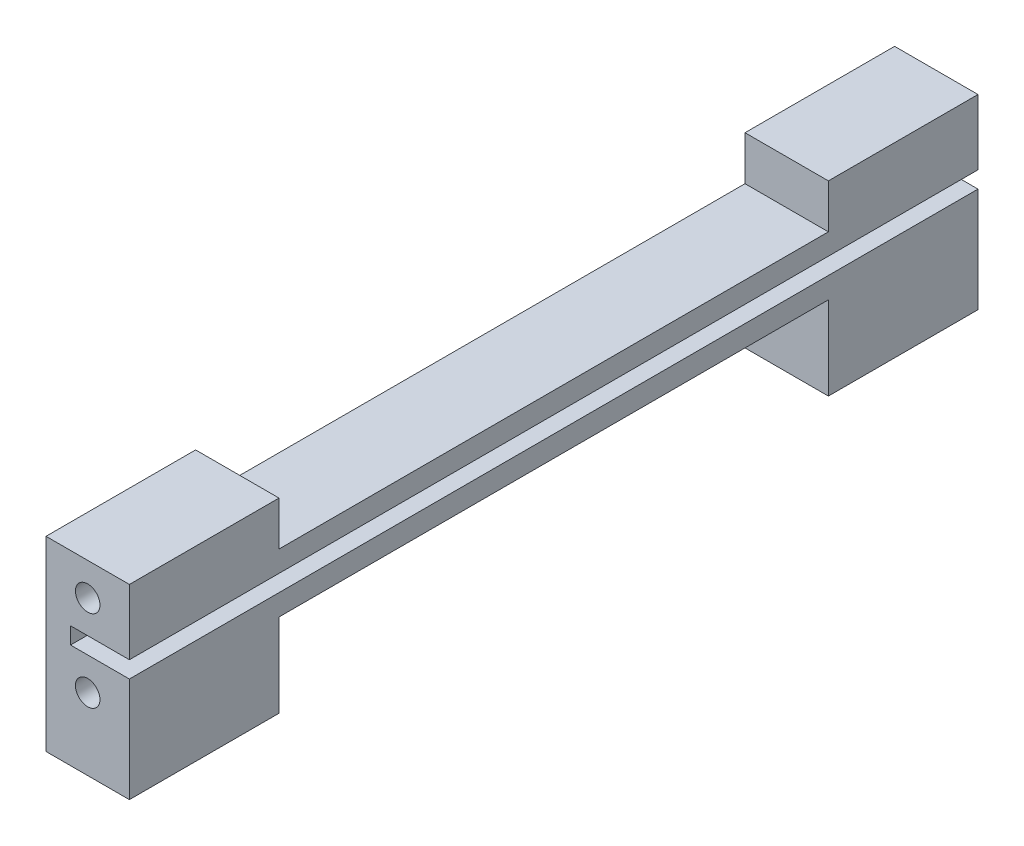
from build123d import *

# Parameters (mm, degrees)
BOSS_EXTRUDE2_DEPTH            = 8.5
SKETCH6_W                      = 6
SKETCH6_H                      = 1.7
CUT_EXTRUDE3_DEPTH             = 87.5
M3X0_5_TAPPED_HOLE4_AT_2_COUNT = 2
M3X0_5_TAPPED_HOLE4_AT_2_PITCH = 8.35
SKETCH20_W                     = 8.5
SKETCH20_H                     = 15.25
BOSS_EXTRUDE3_DEPTH            = 4
SKETCH23_W                     = 8.5
SKETCH23_H                     = 15.25
BOSS_EXTRUDE4_DEPTH            = 4


with BuildPart() as part:
    # Sketch5 → Boss-Extrude2 (new body)
    with BuildSketch(Plane(origin=(0, 0, 0), x_dir=(0, 0, -1), z_dir=(1, 0, 0))):
        Polygon((0, 0), (15.25, 0), (15.25, 4.5), (71.25, 4.5), (71.25, 0), (86.5, 0), (86.5, 15), (71.25, 15), (71.25, 10.5), (15.25, 10.5), (15.25, 15), (0, 15), align=None)
    extrude(amount=BOSS_EXTRUDE2_DEPTH)

    # Sketch6 → Cut-Extrude3 (cut, through all)
    with BuildSketch(Plane.XY):
        with Locations((5.5, 7.5)):
            Rectangle(SKETCH6_W, SKETCH6_H)
    extrude(amount=-CUT_EXTRUDE3_DEPTH, mode=Mode.SUBTRACT)

    # Sketch18 → M3x0.5 Tapped Hole4 (revolve, cut)
    with BuildSketch(Plane(origin=(4.25, 3.325, 0), x_dir=(0, -1, 0), z_dir=(1, 0, 0))):
        Polygon((0, 0), (0, 6.751075774), (1.25, 6), (1.25, 0), align=None)
    m3x0_5_tapped_hole4 = revolve(axis=Axis((4.25, 3.325, 6.35), (0, 0, -1)), mode=Mode.SUBTRACT)

    # M3x0.5 Tapped Hole4 at 2: M3x0.5 Tapped Hole4 ×2
    with Locations(*[(0, i * M3X0_5_TAPPED_HOLE4_AT_2_PITCH, 0) for i in range(1, M3X0_5_TAPPED_HOLE4_AT_2_COUNT)]):
        add(m3x0_5_tapped_hole4, mode=Mode.SUBTRACT)

    # Mirror3: M3x0.5 Tapped Hole4 across plane
    add(m3x0_5_tapped_hole4.mirror(Plane(origin=(0, 0, -43.25), x_dir=(1, 0, 0), z_dir=(0, 0, -1))), mode=Mode.SUBTRACT)

    # Mirror3 copy 1 sketch → Mirror3 copy 1 (revolve, cut)
    with BuildSketch(Plane(origin=(4.25, 11.675, -86.5), x_dir=(0, -1, 0), z_dir=(1, 0, 0))):
        Polygon((0, 0), (0, -6.751075774), (1.25, -6), (1.25, 0), align=None)
    revolve(axis=Axis((4.25, 11.675, -92.85), (0, 0, -1)), mode=Mode.SUBTRACT)

    # Sketch20 → Boss-Extrude3 (add)
    with BuildSketch(Plane.XZ):
        with Locations((4.25, -7.625)):
            Rectangle(SKETCH20_W, SKETCH20_H)
    extrude(amount=BOSS_EXTRUDE3_DEPTH)

    # Sketch23 → Boss-Extrude4 (add)
    with BuildSketch(Plane.XZ):
        with Locations((4.25, -78.875)):
            Rectangle(SKETCH23_W, SKETCH23_H)
    extrude(amount=BOSS_EXTRUDE4_DEPTH)


solid = part.part
